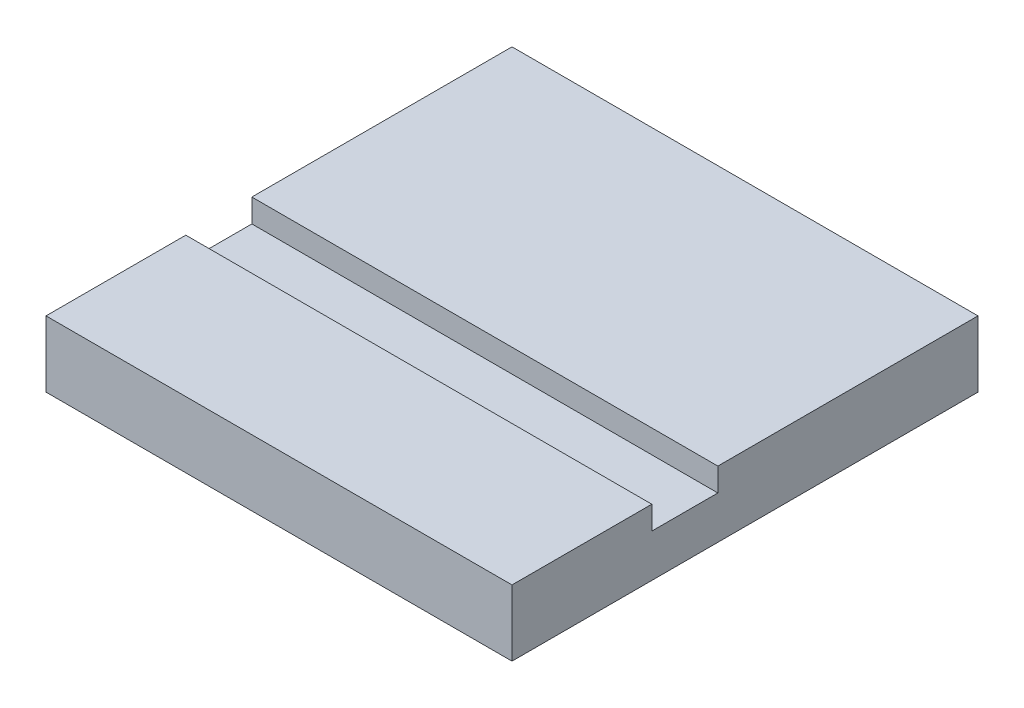
from build123d import *

# Parameters (mm, degrees)
SKETCH1_W           = 127
SKETCH1_H           = 127
BOSS_EXTRUDE1_DEPTH = 18
SKETCH2_W           = 127
SKETCH2_H           = 18
CUT_EXTRUDE1_DEPTH  = 6.35


with BuildPart() as part:
    # Sketch1 → Boss-Extrude1 (new body)
    with BuildSketch(Plane(origin=(0, 0, 0), x_dir=(1, 0, 0), z_dir=(0, 1, 0))):
        Rectangle(SKETCH1_W, SKETCH1_H)
    extrude(amount=BOSS_EXTRUDE1_DEPTH)

    # Sketch2 → Cut-Extrude1 (cut)
    with BuildSketch(Plane(origin=(0, 18, 0), x_dir=(1, 0, 0), z_dir=(0, 1, 0))):
        with Locations((0, -16.4)):
            Rectangle(SKETCH2_W, SKETCH2_H)
    extrude(amount=-CUT_EXTRUDE1_DEPTH, mode=Mode.SUBTRACT)


solid = part.part
